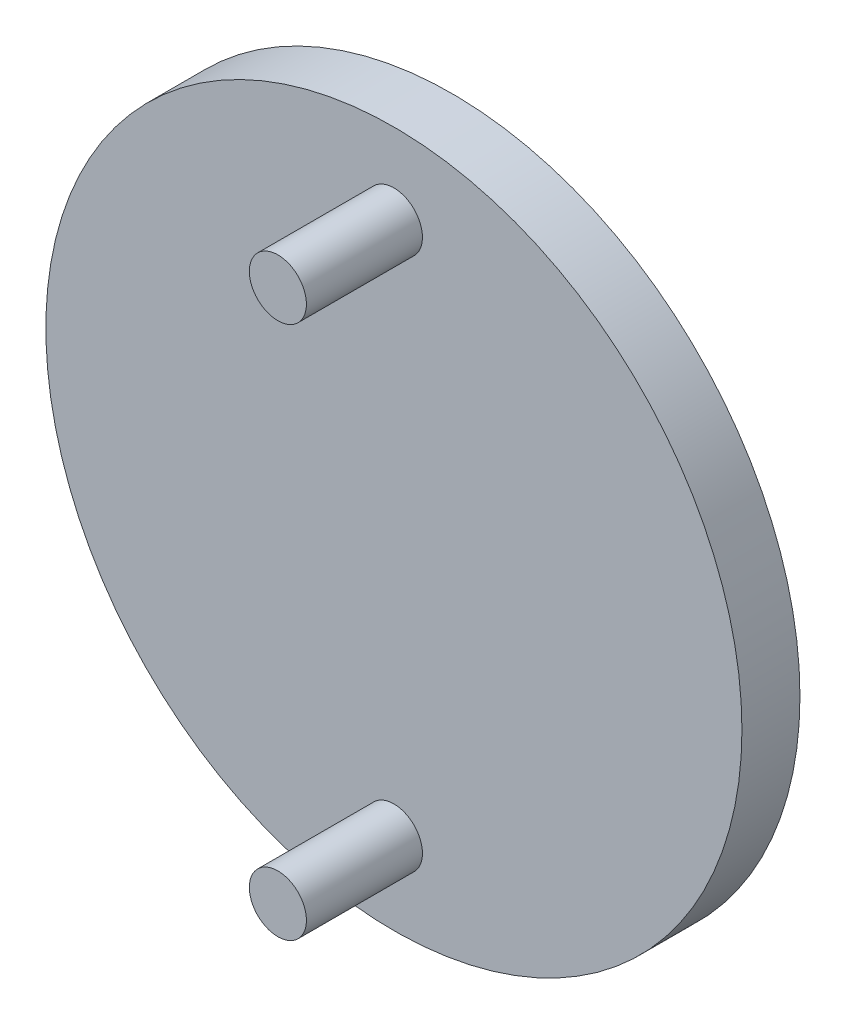
from build123d import *

# Parameters (mm, degrees)
SKETCH1_R           = 60
BOSS_EXTRUDE1_DEPTH = 10
SKETCH2_R           = 4.92
BOSS_EXTRUDE2_DEPTH = 30
CIRPATTERN1_COUNT   = 2


with BuildPart() as part:
    # Sketch1 → Boss-Extrude1 (new body)
    with BuildSketch(Plane.XY):
        Circle(SKETCH1_R)
    extrude(amount=BOSS_EXTRUDE1_DEPTH)

    # Sketch2 → Boss-Extrude2 (add)
    with BuildSketch(Plane.XY):
        with Locations((0, 45.984931592)):
            Circle(SKETCH2_R)
    boss_extrude2 = extrude(amount=BOSS_EXTRUDE2_DEPTH)

    # CirPattern1: Boss-Extrude2 ×2 about axis
    cirpattern1_axis = Axis((0, 0, 10), (0, 0, -1))
    for i in range(1, CIRPATTERN1_COUNT):
        add(boss_extrude2.rotate(cirpattern1_axis, i * 360 / CIRPATTERN1_COUNT))


solid = part.part
